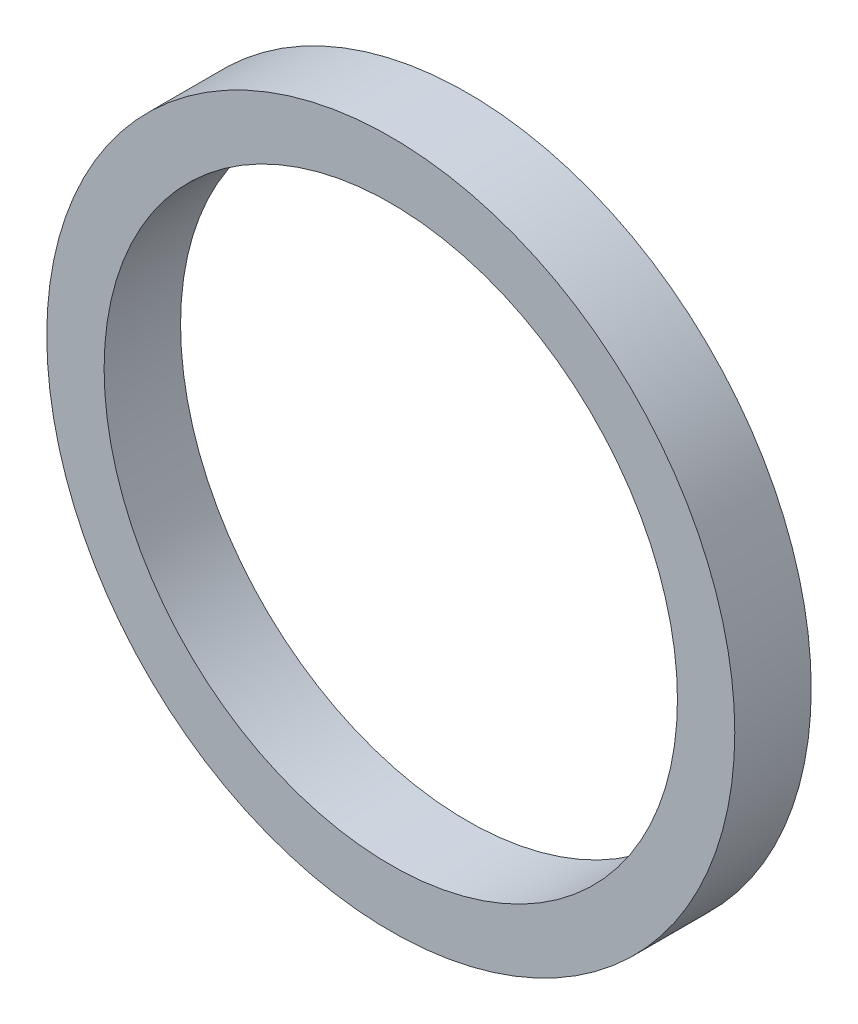
from build123d import *

# Parameters (mm, degrees)
SKETCH1_R           = 2.8575
SKETCH1_R_2         = 2.38125
BOSS_EXTRUDE1_DEPTH = 0.635


with BuildPart() as part:
    # Sketch1 → Boss-Extrude1 (new body)
    with BuildSketch(Plane.XY):
        Circle(SKETCH1_R)
        Circle(SKETCH1_R_2, mode=Mode.SUBTRACT)
    extrude(amount=BOSS_EXTRUDE1_DEPTH)


solid = part.part
